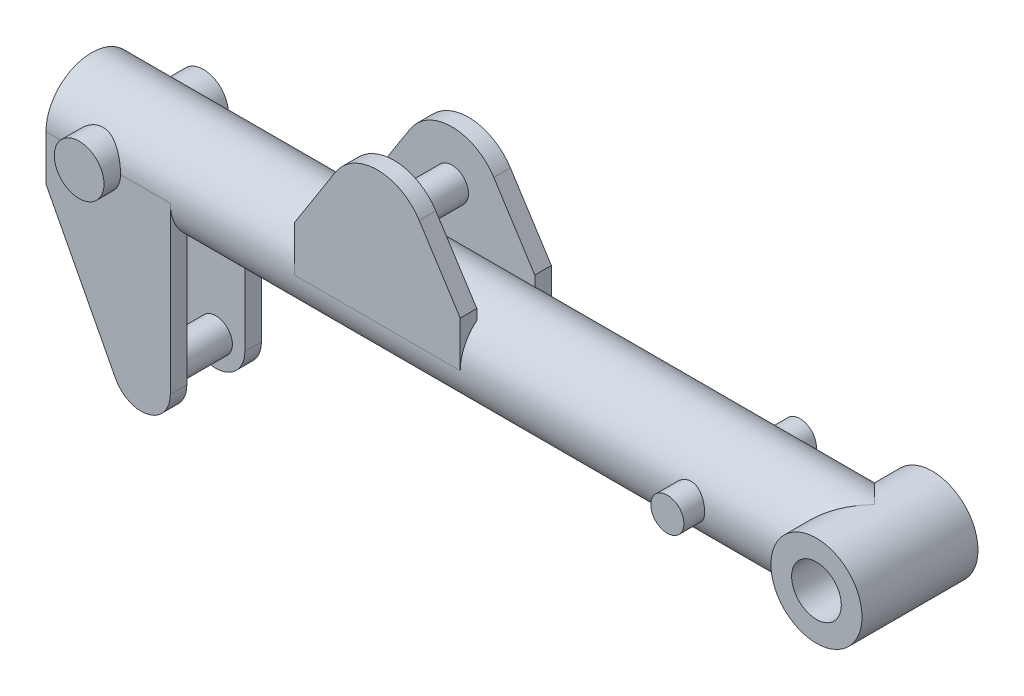
from build123d import *

# Parameters (mm, degrees)
SKETCH1_R             = 55
BOSS_EXTRUDE1_DEPTH   = 1000
SHELL1_T              = 10
BOSS_EXTRUDE2_DEPTH   = 20
BOSS_EXTRUDE2_2_DEPTH = 20
SKETCH5_R             = 55
BOSS_EXTRUDE3_DEPTH   = 70
SKETCH6_R             = 30
CUT_EXTRUDE2_DEPTH    = 141
SKETCH2_R             = 30
BOSS_EXTRUDE4_DEPTH   = 75
SKETCH7_R             = 20
BOSS_EXTRUDE5_DEPTH   = 55
SKETCH8_R             = 20
BOSS_EXTRUDE6_DEPTH   = 80


with BuildPart() as part:
    # Sketch1 → Boss-Extrude1 (new body)
    with BuildSketch(Plane(origin=(0, 0, 0), x_dir=(0, 0, -1), z_dir=(1, 0, 0))):
        Circle(SKETCH1_R)
    extrude(amount=BOSS_EXTRUDE1_DEPTH)

    # Shell1 (no face opened: a closed hollow body)
    add(offset(amount=-SHELL1_T, mode=Mode.PRIVATE), mode=Mode.SUBTRACT)


with BuildPart() as body_2:
    # Sketch3 → Boss-Extrude2 (new body)
    with BuildSketch(Plane.XY.offset(55)):
        with BuildLine():
            Line((300, 0), (300, 55))
            Line((300, 55), (349.453051, 132.326552))
            ThreePointArc((349.453051, 132.326552), (400, 160), (450.546949, 132.326552))
            Line((450.546949, 132.326552), (500, 55))
            Line((500, 55), (500, 0))
            Line((500, 0), (300, 0))
        make_face()
    boss_extrude2 = extrude(amount=-BOSS_EXTRUDE2_DEPTH)


with BuildPart() as body_3:
    # Sketch3 → Boss-Extrude2 2 (new body)
    with BuildSketch(Plane.XY.offset(55)):
        with BuildLine():
            Line((150, 0), (150, -55))
            Line((150, -55), (150, -200))
            ThreePointArc((150, -200), (123.323935, -233.995766), (83.959309, -216.170203))
            Line((83.959309, -216.170203), (0, -55))
            Line((0, -55), (0, 0))
            Line((0, 0), (150, 0))
        make_face()
    boss_extrude2_2 = extrude(amount=-BOSS_EXTRUDE2_2_DEPTH)


with BuildPart() as part_1:
    add(part.part)

    # Mirror2: Boss-Extrude2, Boss-Extrude2 2 across plane
    add(boss_extrude2.mirror(Plane.XY))
    add(boss_extrude2_2.mirror(Plane.XY))

    # Sketch5 → Boss-Extrude3 (add, symmetric)
    with BuildSketch(Plane.XY):
        with Locations((945, 0)):
            Circle(SKETCH5_R)
    extrude(amount=BOSS_EXTRUDE3_DEPTH, both=True)

    # Sketch6 → Cut-Extrude2 (cut, through all)
    with BuildSketch(Plane.XY.offset(70)):
        with Locations((945, 0)):
            Circle(SKETCH6_R)
        with BuildLine():
            Line((1000, 0), (1000, 55))
            Line((1000, 55), (945, 55))
            ThreePointArc((945, 55), (983.890873, 38.890873), (1000, 0))
        make_face()
        with BuildLine():
            Line((1000, -55), (1000, 0))
            ThreePointArc((1000, 0), (983.890873, -38.890873), (945, -55))
            Line((945, -55), (1000, -55))
        make_face()
    extrude(amount=-CUT_EXTRUDE2_DEPTH, mode=Mode.SUBTRACT)

    # Sketch2 → Boss-Extrude4 (add, symmetric)
    with BuildSketch(Plane.XY):
        with Locations((60, 0)):
            Circle(SKETCH2_R)
    extrude(amount=BOSS_EXTRUDE4_DEPTH, both=True)

    add(body_2.part)  # Boss-Extrude5 merges body 2

    add(body_3.part)  # Boss-Extrude5 merges body 3
    # Sketch7 → Boss-Extrude5 (add, symmetric)
    with BuildSketch(Plane.XY):
        with Locations((400, 100)):
            Circle(SKETCH7_R)
        with Locations((115, -200)):
            Circle(SKETCH7_R)
    extrude(amount=BOSS_EXTRUDE5_DEPTH, both=True)

    # Sketch8 → Boss-Extrude6 (add, symmetric)
    with BuildSketch(Plane.XY):
        with Locations((775, 0)):
            Circle(SKETCH8_R)
    extrude(amount=BOSS_EXTRUDE6_DEPTH, both=True)


solid = part_1.part
